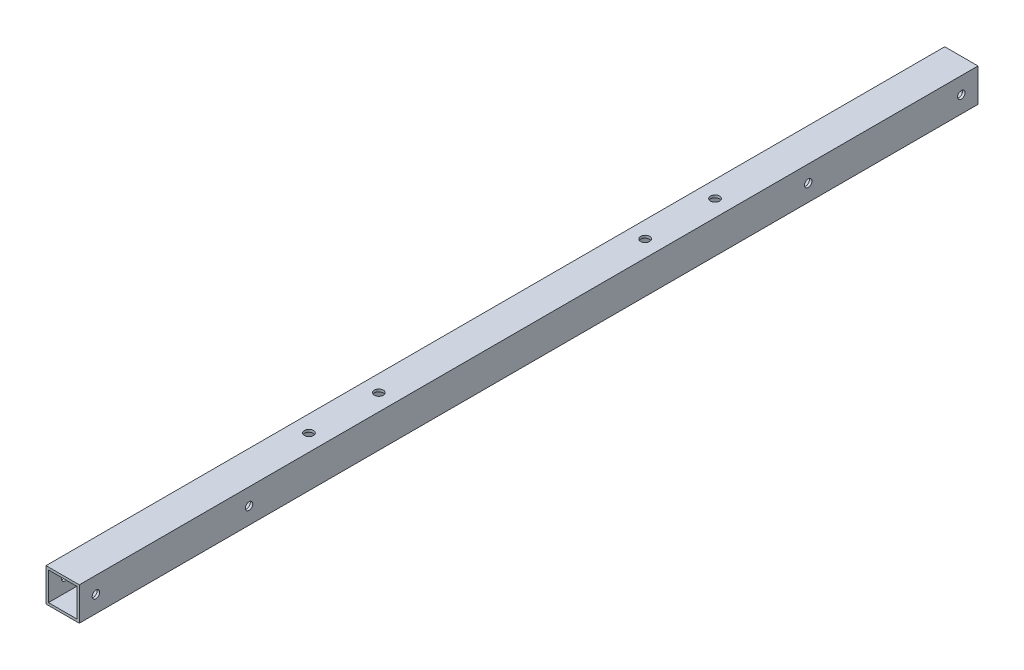
from build123d import *

# Parameters (mm, degrees)
SKETCH_1_W                  = 20
SKETCH_1_H                  = 20
SKETCH_1_W_2                = 17
SKETCH_1_H_2                = 17
EXTRUDE_1_DEPTH             = 540
SKETCH_3_R                  = 2.25
CUT_EXTRUDE_2_DEPTH         = 20
HOLE_WIZARD_5_4_5_4_1_D     = 5.4
HOLE_WIZARD_10_0_10_1_D     = 10
HOLE_WIZARD_10_0_10_1_DEPTH = 1.5


with BuildPart() as part:
    # ｽｹｯﾁ1 → ﾎﾞｽ - 押し出し1 (new body)
    with BuildSketch(Plane.XY):
        Rectangle(SKETCH_1_W, SKETCH_1_H)
        Rectangle(SKETCH_1_W_2, SKETCH_1_H_2, mode=Mode.SUBTRACT)
    extrude(amount=EXTRUDE_1_DEPTH)

    # ｽｹｯﾁ3 → ｶｯﾄ - 押し出し2 (cut)
    with BuildSketch(Plane(origin=(10, 0, 0), x_dir=(0, 0, -1), z_dir=(1, 0, 0))):
        with Locations((-530, 0)):
            Circle(SKETCH_3_R)
        with Locations((-438, 0)):
            Circle(SKETCH_3_R)
        with Locations((-102, 0)):
            Circle(SKETCH_3_R)
        with Locations((-10, 0)):
            Circle(SKETCH_3_R)
    extrude(amount=-CUT_EXTRUDE_2_DEPTH, mode=Mode.SUBTRACT)

    # Ø5.4 (5.4) 直径の穴1 (through all)
    with Locations(Plane(origin=(0, 10, 0), x_dir=(1, 0, 0), z_dir=(0, 1, 0))):
        with Locations((0, -148), (0, -190), (0, -350), (0, -392)):
            Hole(HOLE_WIZARD_5_4_5_4_1_D / 2)

    # Ø10.0 (10) 直径の穴1
    with Locations(Plane(origin=(0, -10, 0), x_dir=(-1, 0, 0), z_dir=(0, -1, 0))):
        with Locations((0, -148), (0, -190), (0, -350), (0, -392)):
            Hole(HOLE_WIZARD_10_0_10_1_D / 2, depth=HOLE_WIZARD_10_0_10_1_DEPTH)


solid = part.part
